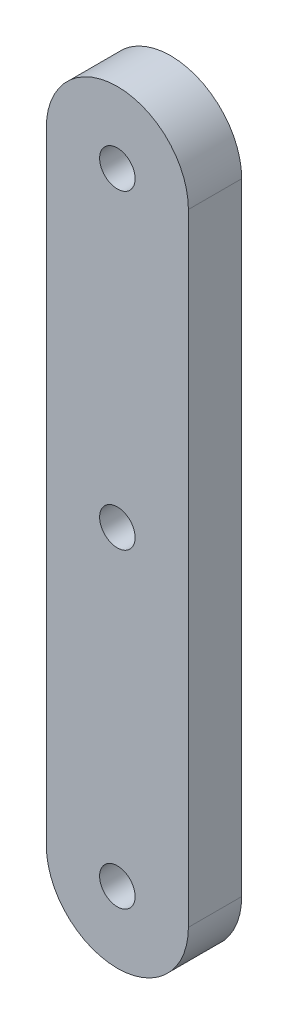
from build123d import *

# Parameters (mm, degrees)
MODEL_R             = 1
BOSS_EXTRUDE1_DEPTH = 3


with BuildPart() as part:
    # Model → Boss-Extrude1 (new body)
    with BuildSketch(Plane.XY):
        with BuildLine():
            Line((31.793664427, 45.689933635), (31.793664427, 10.689933635))
            ThreePointArc((31.793664427, 10.689933635), (35.793664427, 6.689933635), (39.793664427, 10.689933635))
            Line((39.793664427, 10.689933635), (39.793664427, 45.689933635))
            ThreePointArc((39.793664427, 45.689933635), (35.793664427, 49.689933635), (31.793664427, 45.689933635))
        make_face()
        with Locations((35.793664427, 10.689933635)):
            Circle(MODEL_R, mode=Mode.SUBTRACT)
        with Locations((35.793664427, 45.689933635)):
            Circle(MODEL_R, mode=Mode.SUBTRACT)
        with Locations((35.793664427, 28.189933635)):
            Circle(MODEL_R, mode=Mode.SUBTRACT)
    extrude(amount=BOSS_EXTRUDE1_DEPTH)


solid = part.part
